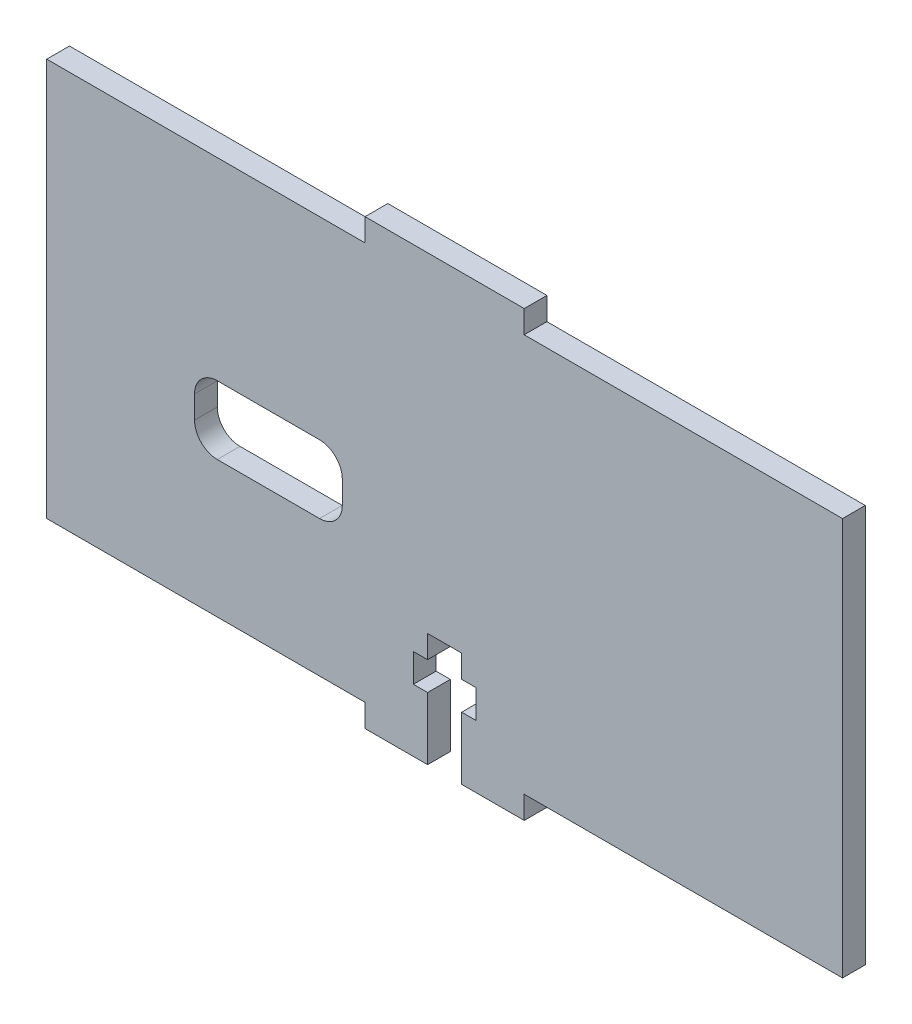
from build123d import *

# Parameters (mm, degrees)
SKETCH1_W                   = 13
SKETCH1_H                   = 6
MAIN_SLIDER_SIDE_UP_DEPTH   = 2
SLIDER_SIDE_UP_CONTOURING_R = 2


with BuildPart() as part:
    # Sketch1 → Main Slider Side Up (new body)
    with BuildSketch(Plane.XY):
        Polygon((42, 35), (70, 35), (70, 0), (42, 0), (42, -2), (36.5, -2), (36.5, 3.5), (37.75, 3.5), (37.75, 6), (36.5, 6), (36.5, 8), (33.5, 8), (33.5, 6), (32.25, 6), (32.25, 3.5), (33.5, 3.5), (33.5, -2), (28, -2), (28, 0), (0, 0), (0, 35), (28, 35), (28, 37), (42, 37), align=None)
        with Locations((19.5, 15)):
            Rectangle(SKETCH1_W, SKETCH1_H, mode=Mode.SUBTRACT)
    extrude(amount=MAIN_SLIDER_SIDE_UP_DEPTH)

    # Slider Side Up Contouring
    slider_side_up_contouring_edges = [part.edges().sort_by_distance(p)[0] for p in [
        (26, 12, 1),
        (26, 18, 1),
        (13, 18, 1),
        (13, 12, 1),
    ]]
    fillet(slider_side_up_contouring_edges, radius=SLIDER_SIDE_UP_CONTOURING_R)


solid = part.part
